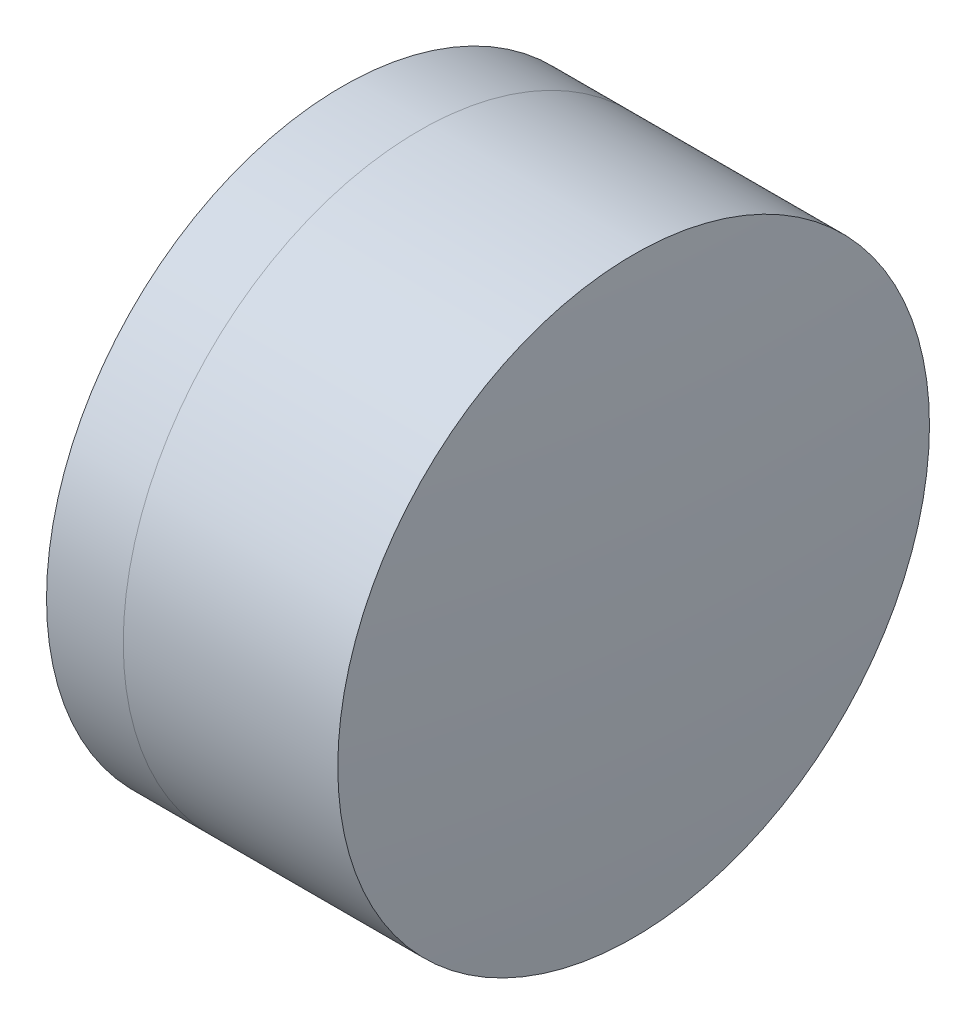
from build123d import *


with BuildPart() as part:
    # 草图1 one side → 旋转1 (revolve)
    with BuildSketch(Plane(origin=(0, 0, 0), x_dir=(1, 0, 0), z_dir=(0, 1, 0)), mode=Mode.PRIVATE) as revolve_1_sk:
        with BuildLine():
            ThreePointArc((-0.903101889, 3.175), (-1.462656208, 1.631127932), (-1.652560574, 0))
            Line((-1.652560574, 0), (0.847439426, 0))
            ThreePointArc((0.847439426, 0), (0.610914366, 1.653799143), (-0.079696711, 3.175))
            Line((-0.079696711, 3.175), (-0.903101889, 3.175))
        make_face()
    revolve(revolve_1_sk.sketch.rotate(Axis((-9.702612178, 0, 0), (1, 0, 0)), 180), axis=Axis((-9.702612178, 0, 0), (1, 0, 0)))  # turned: the seam where the file's is


with BuildPart() as body_2:
    # 草图2 one side → 旋转3 (revolve)
    with BuildSketch(Plane(origin=(0, 0, 0), x_dir=(1, 0, 0), z_dir=(0, 1, 0)), mode=Mode.PRIVATE) as revolve_3_sk:
        with BuildLine():
            Line((2.222485981, 3.175), (-0.079696711, 3.175))
            ThreePointArc((-0.079696711, 3.175), (0.610914366, 1.653799143), (0.847439426, 0))
            Line((0.847439426, 0), (2.347439426, 0))
            ThreePointArc((2.347439426, 0), (2.316188978, 1.588728923), (2.222485981, 3.175))
        make_face()
    revolve(revolve_3_sk.sketch.rotate(Axis((-0.551919993, 0, 0), (1, 0, 0)), 180), axis=Axis((-0.551919993, 0, 0), (1, 0, 0)))  # turned: the seam where the file's is


solid = Compound([part.part, body_2.part])
